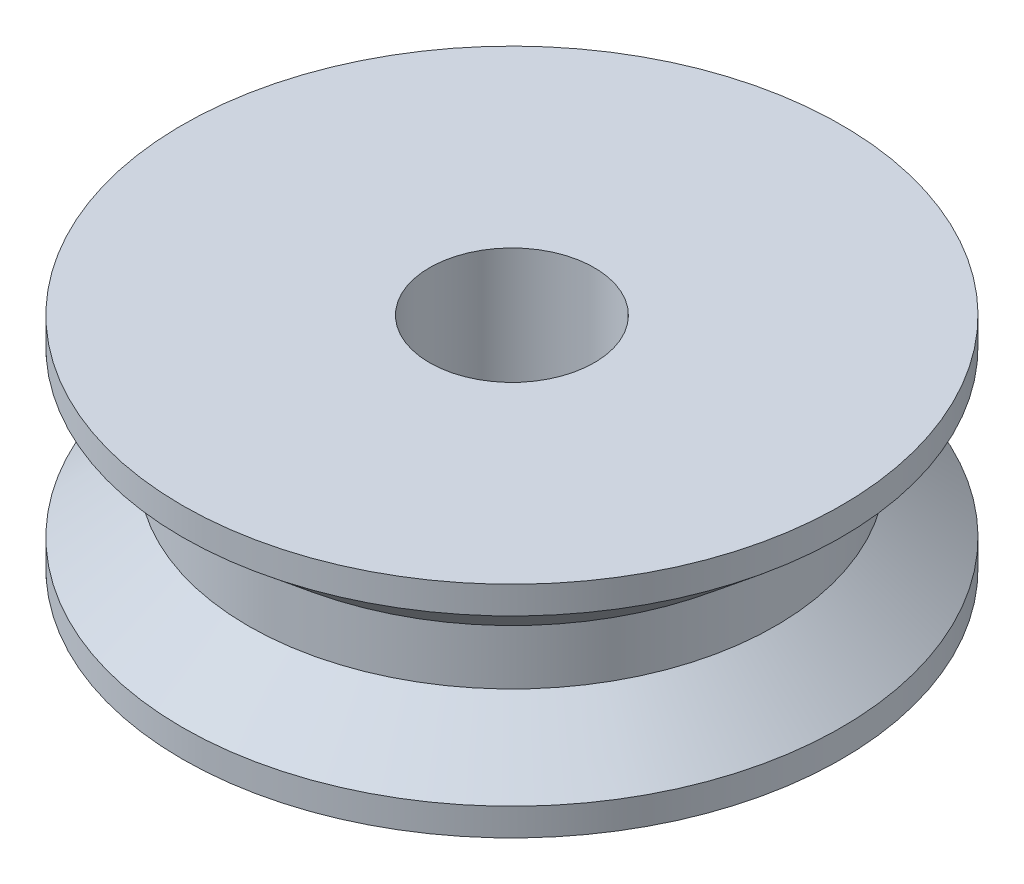
from build123d import *

# Parameters (mm, degrees)
SKETCH1_R       = 6
SKETCH1_R_2     = 1.5
MAIN_BODY_DEPTH = 4


with BuildPart() as part:
    # Sketch1 → Main Body (new body)
    with BuildSketch(Plane(origin=(0, 0, 0), x_dir=(1, 0, 0), z_dir=(0, 1, 0))):
        Circle(SKETCH1_R)
        Circle(SKETCH1_R_2, mode=Mode.SUBTRACT)
    extrude(amount=MAIN_BODY_DEPTH)

    # Sketch6 → Tendon Guide (revolve, cut)
    with BuildSketch(Plane.XY):
        Polygon((6, 0.5), (6, 3.5), (4.8, 2.5), (4.8, 1.5), align=None)
    revolve(axis=Axis((0, 4, 0), (0, -1, 0)), mode=Mode.SUBTRACT)


solid = part.part
